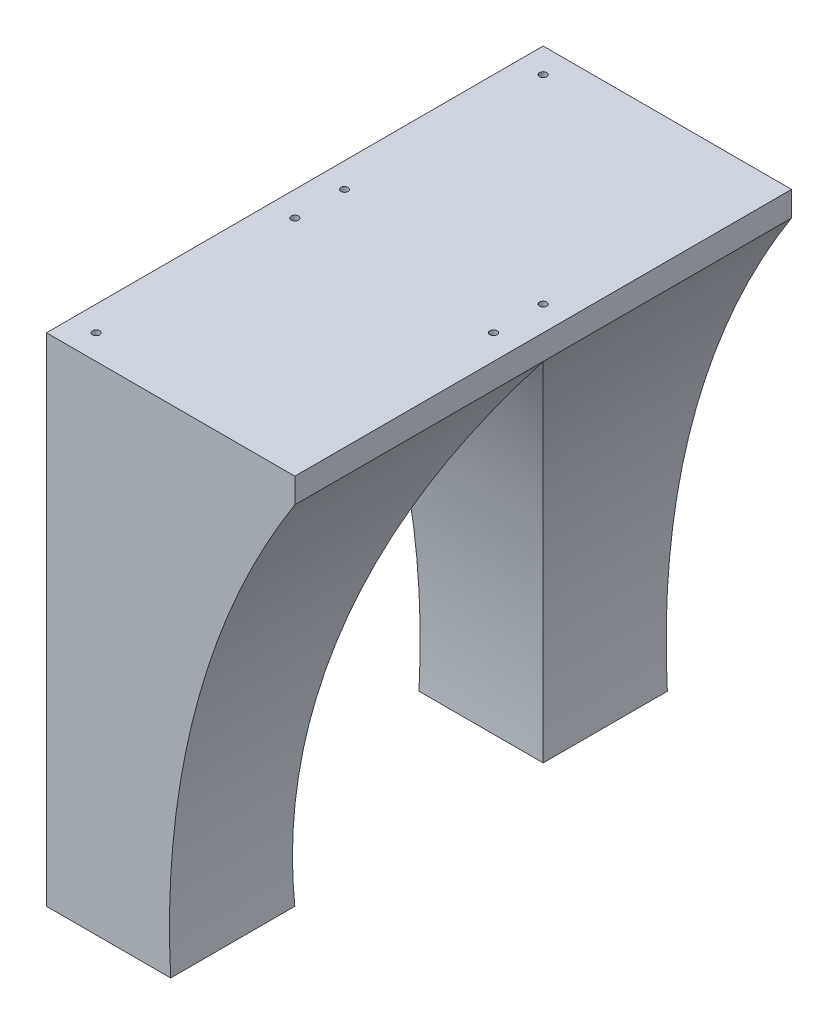
from build123d import *

# Parameters (mm, degrees)
SKETCH1_W           = 100
SKETCH1_H           = 100
BOSS_EXTRUDE1_DEPTH = 200
CUT_EXTRUDE1_DEPTH  = 200
CUT_EXTRUDE2_DEPTH  = 200
SKETCH4_R           = 1.45
CUT_EXTRUDE3_DEPTH  = 10


with BuildPart() as part:
    # Sketch1 → Boss-Extrude1 (new body)
    with BuildSketch(Plane(origin=(0, 0, 0), x_dir=(1, 0, 0), z_dir=(0, 1, 0))):
        with Locations((50, 50)):
            Rectangle(SKETCH1_W, SKETCH1_H)
    extrude(amount=-BOSS_EXTRUDE1_DEPTH)

    # Sketch2 → Cut-Extrude1 (cut)
    with BuildSketch(Plane.XY):
        with BuildLine():
            ThreePointArc((100, -10), (60.05758303, -101.067785008), (50, -200))
            Line((50, -200), (100, -200))
            Line((100, -200), (100, -10))
        make_face()
    extrude(amount=-CUT_EXTRUDE1_DEPTH, mode=Mode.SUBTRACT)

    # Sketch3 → Cut-Extrude2 (cut)
    with BuildSketch(Plane.ZY):
        with BuildLine():
            ThreePointArc((-50, -200), (-60.05758303, -101.067785008), (-100, -10))
            Line((-100, -10), (-100, -200))
            Line((-100, -200), (-50, -200))
        make_face()
    extrude(amount=-CUT_EXTRUDE2_DEPTH, mode=Mode.SUBTRACT)

    # Sketch4 → Cut-Extrude3 (cut)
    with BuildSketch(Plane(origin=(0, 0, 0), x_dir=(1, 0, 0), z_dir=(0, 1, 0))):
        with Locations((10, 90)):
            Circle(SKETCH4_R)
        with Locations((90, 90)):
            Circle(SKETCH4_R)
        with Locations((10, 10)):
            Circle(SKETCH4_R)
    extrude(amount=-CUT_EXTRUDE3_DEPTH, mode=Mode.SUBTRACT)

    # Mirror1: part across plane


with BuildPart() as part_1:
    add(part.part)
    add(part.part.mirror(Plane(origin=(0, -200, -100), x_dir=(1, 0, 0), z_dir=(0, 0, -1))))


solid = part_1.part
